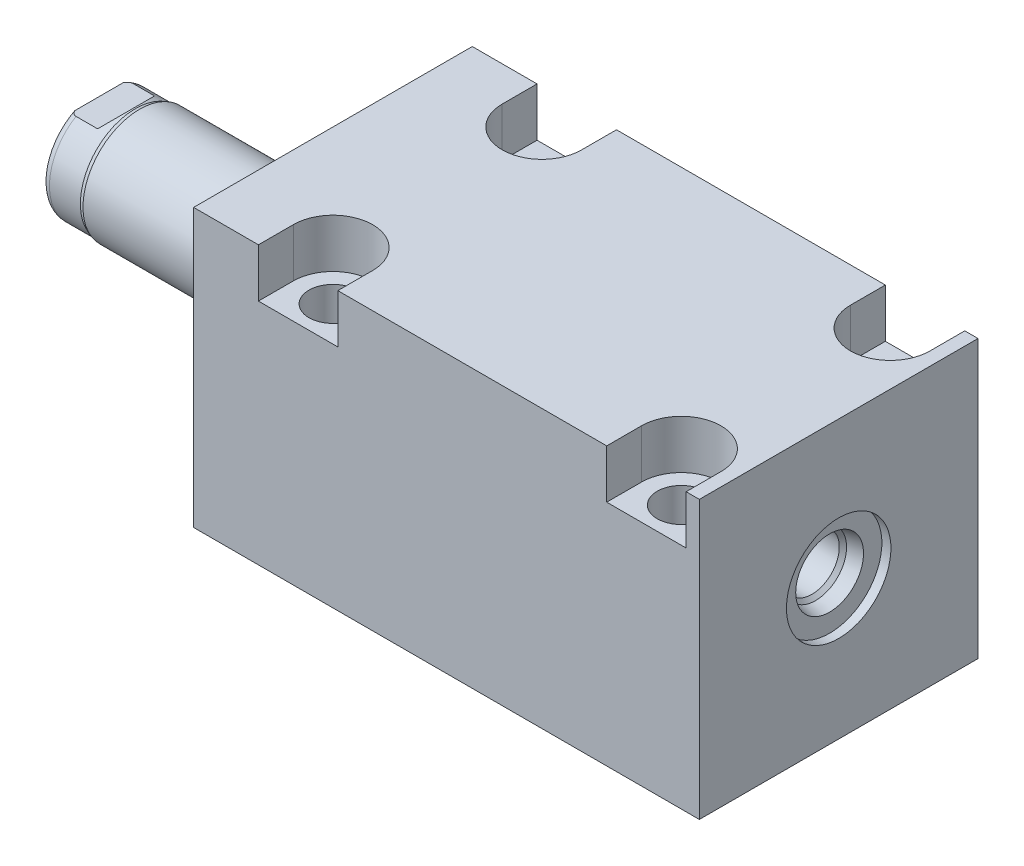
from build123d import *

# Parameters (mm, degrees)
SKETCH1_W          = 50.8
SKETCH1_H          = 50.546
EXTRUDE1_DEPTH     = 92.202
SKETCH5_R          = 17.4625
EXTRUDE2_DEPTH     = 5.969
SKETCH6_W          = 10.31875
SKETCH6_H          = 36.703
CUT_EXTRUDE4_DEPTH = 30.48
HOLE2_D            = 8.7376
HOLE2_DEPTH        = 50.546
LPATTERN1_COUNT    = 2
LPATTERN1_PITCH    = 63.5
CUT_EXTRUDE5_DEPTH = 8.89
HOLE3_D            = 3.175
HOLE3_DEPTH        = 11.303
HOLE3_CBORE_D      = 11.3411
HOLE3_CBORE_DEPTH  = 1.4478
HOLE3_TIP          = 0.953866233
HOLE4_D            = 3.175
HOLE4_DEPTH        = 13.8684
HOLE4_CBORE_D      = 11.3411
HOLE4_CBORE_DEPTH  = 1.4478
HOLE4_TIP          = 0.953866233
CHAMFER1_SIZE      = 0.635
SKETCH23_R         = 1.4478
LPATTERN3_COUNT    = 2
LPATTERN3_PITCH    = 63.5


with BuildPart() as part:
    # Sketch1 → Extrude1 (new body)
    with BuildSketch(Plane(origin=(0, 0, 0), x_dir=(0, 0, -1), z_dir=(1, 0, 0))):
        with Locations((0, -0.127)):
            Rectangle(SKETCH1_W, SKETCH1_H)
    extrude(amount=EXTRUDE1_DEPTH)

    # Sketch5 → Extrude2 (add)
    with BuildSketch(Plane.ZY):
        Circle(SKETCH5_R)
    extrude(amount=EXTRUDE2_DEPTH)

    # Sketch6 → Revolve1 (revolve)
    with BuildSketch(Plane(origin=(0, 0, 0), x_dir=(0, 0, 1), z_dir=(0, -1, 0)), mode=Mode.PRIVATE) as revolve1_sk:
        with Locations((-5.159375, 24.3205)):
            Rectangle(SKETCH6_W, SKETCH6_H)
    revolve(revolve1_sk.sketch.rotate(Axis((5.754582971, 0, 0), (-1, 0, 0)), 180), axis=Axis((5.754582971, 0, 0), (-1, 0, 0)))  # turned: the seam where the file's is

    # S2D0001 → Cut-Revolve4 (revolve, cut)
    with BuildSketch(Plane(origin=(-18.511260017, 3.2639, 0), x_dir=(0, 1, 0), z_dir=(0, 0, 1)), mode=Mode.PRIVATE) as cut_revolve4_sk:
        Polygon((0, 22.225), (0, 9.098539983), (-3.2639, 9.098539983), (-3.2639, 24.160739983), (1.1176, 24.160739983), align=None)
    revolve(cut_revolve4_sk.sketch.rotate(Axis((0, 0, 0), (-1, 0, 0)), 90), axis=Axis((0, 0, 0), (-1, 0, 0)), mode=Mode.SUBTRACT)  # turned: the seam where the file's is

    # Sketch8 → Cut-Revolve5 (revolve, cut)
    with BuildSketch(Plane(origin=(0, 0, 0), x_dir=(0, 0, -1), z_dir=(0, 1, 0)), mode=Mode.PRIVATE) as cut_revolve5_sk:
        with BuildLine():
            Line((-10.31875, 35.2552), (-10.033, 36.0172))
            Line((-10.033, 36.0172), (-10.033, 41.656))
            ThreePointArc((-10.033, 41.656), (-9.932678675, 42.199796865), (-9.644922533, 42.672))
            Line((-9.644922533, 42.672), (-10.31875, 42.672))
            Line((-10.31875, 42.672), (-10.31875, 35.2552))
        make_face()
    revolve(cut_revolve5_sk.sketch.rotate(Axis((-12.65936, 0, 0), (-1, 0, 0)), 180), axis=Axis((-12.65936, 0, 0), (-1, 0, 0)), mode=Mode.SUBTRACT)  # turned: the seam where the file's is

    # Sketch12 → Cut-Extrude4 (cut, symmetric)
    with BuildSketch(Plane(origin=(0, 0, 0), x_dir=(0, -1, 0), z_dir=(0, 0, -1))):
        Polygon((8.5852, 42.672), (8.5852, 37.719), (10.033, 36.2712), (10.033, 42.672), align=None)
        Polygon((-8.5852, 42.672), (-8.5852, 37.719), (-10.033, 36.2712), (-10.033, 42.672), align=None)
    extrude(amount=CUT_EXTRUDE4_DEPTH, both=True, mode=Mode.SUBTRACT)

    # Hole2
    with Locations(Plane(origin=(0, 25.146, 0), x_dir=(-1, 0, 0), z_dir=(0, 1, 0))):
        with Locations((-19.05, -19.05), (-19.05, 19.05)):
            hole2 = Hole(HOLE2_D / 2, depth=HOLE2_DEPTH)

    # LPattern1: Hole2 ×2
    with Locations(*[(i * LPATTERN1_PITCH, 0, 0) for i in range(1, LPATTERN1_COUNT)]):
        add(hole2, mode=Mode.SUBTRACT)

    # Sketch18 → Cut-Extrude5 (cut)
    with BuildSketch(Plane(origin=(0, 25.146, 0), x_dir=(1, 0, 0), z_dir=(0, 1, 0))):
        with BuildLine():
            Line((89.789, -25.4), (75.311, -25.4))
            Line((75.311, -25.4), (75.311, -19.05))
            ThreePointArc((75.311, -19.05), (82.55, -11.811), (89.789, -19.05))
            Line((89.789, -19.05), (89.789, -25.4))
        make_face()
        with BuildLine():
            Line((11.811, -19.05), (11.811, -25.4))
            Line((11.811, -25.4), (26.289, -25.4))
            Line((26.289, -25.4), (26.289, -19.05))
            ThreePointArc((26.289, -19.05), (19.05, -11.811), (11.811, -19.05))
        make_face()
        with BuildLine():
            Line((89.789, 19.05), (89.789, 25.4))
            Line((89.789, 25.4), (75.311, 25.4))
            Line((75.311, 25.4), (75.311, 19.05))
            ThreePointArc((75.311, 19.05), (82.55, 11.811), (89.789, 19.05))
        make_face()
        with BuildLine():
            Line((26.289, 25.4), (11.811, 25.4))
            Line((11.811, 25.4), (11.811, 19.05))
            ThreePointArc((11.811, 19.05), (19.05, 11.811), (26.289, 19.05))
            Line((26.289, 19.05), (26.289, 25.4))
        make_face()
    extrude(amount=-CUT_EXTRUDE5_DEPTH, mode=Mode.SUBTRACT)

    # Hole3
    with Locations(Plane.XZ.offset(25.4)):
        with Locations((12.7, 0)):
            CounterBoreHole(HOLE3_D / 2, HOLE3_CBORE_D / 2, HOLE3_CBORE_DEPTH, depth=HOLE3_DEPTH)
            with Locations((0, 0, -(HOLE3_DEPTH + HOLE3_TIP / 2))):  # 118° drill point
                Cone(0, HOLE3_D / 2, HOLE3_TIP, mode=Mode.SUBTRACT)

    # Hole4
    with Locations(Plane.XZ.offset(25.4)):
        with Locations((76.2, 0)):
            CounterBoreHole(HOLE4_D / 2, HOLE4_CBORE_D / 2, HOLE4_CBORE_DEPTH, depth=HOLE4_DEPTH)
            with Locations((0, 0, -(HOLE4_DEPTH + HOLE4_TIP / 2))):  # 118° drill point
                Cone(0, HOLE4_D / 2, HOLE4_TIP, mode=Mode.SUBTRACT)

    # Chamfer1
    chamfer1_edges = [part.edges().sort_by_distance(p)[0] for p in [
        (14.2875, -23.9522, 0),
        (77.7875, -23.9522, 0),
    ]]
    chamfer(chamfer1_edges, length=CHAMFER1_SIZE)

    # Sketch24 → Cut-Revolve6 (revolve, cut)
    with BuildSketch(Plane.XY, mode=Mode.PRIVATE) as cut_revolve6_sk:
        Polygon((92.202, 9.525), (90.551, 9.525), (90.551, 6.1849), (87.9983, 5.642306865), (87.334393135, 4.9784), (75.946, 4.9784), (75.946, 0), (92.202, 0), align=None)
    revolve(cut_revolve6_sk.sketch.rotate(Axis((0, 0, 0), (1, 0, 0)), 270), axis=Axis((0, 0, 0), (1, 0, 0)), mode=Mode.SUBTRACT)  # turned: the seam where the file's is


with BuildPart() as body_2:
    # Sketch23 → Revolve2 (revolve)
    with BuildSketch(Plane.XY, mode=Mode.PRIVATE) as revolve2_sk:
        with Locations((8.47725, -25.4)):
            Circle(SKETCH23_R)
    revolve(revolve2_sk.sketch.rotate(Axis((12.7, -23.9522, 0), (0, 1, 0)), 270), axis=Axis((12.7, -23.9522, 0), (0, 1, 0)))  # turned: the seam where the file's is


with BuildPart() as lpattern3_1:
    # LPattern3: pattern copy
    add(body_2.part.moved(Location(Vector(1, 0, 0) * (1 * LPATTERN3_PITCH))))


solid = Compound([part.part, body_2.part, lpattern3_1.part])
